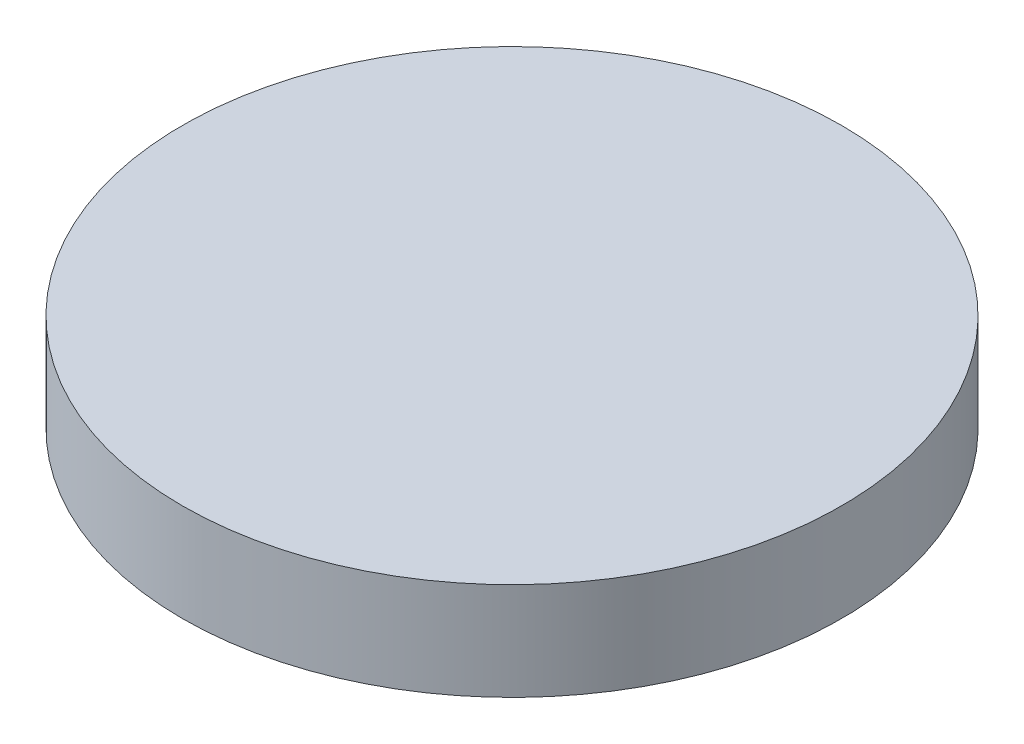
from build123d import *

# Parameters (mm, degrees)
SKETCH_1_R      = 13.5
EXTRUDE_1_DEPTH = 4


with BuildPart() as part:
    # 스케치1 → 보스-돌출1 (new body)
    with BuildSketch(Plane(origin=(0, 0, 0), x_dir=(1, 0, 0), z_dir=(0, 1, 0))):
        Circle(SKETCH_1_R)
    extrude(amount=EXTRUDE_1_DEPTH)


solid = part.part
